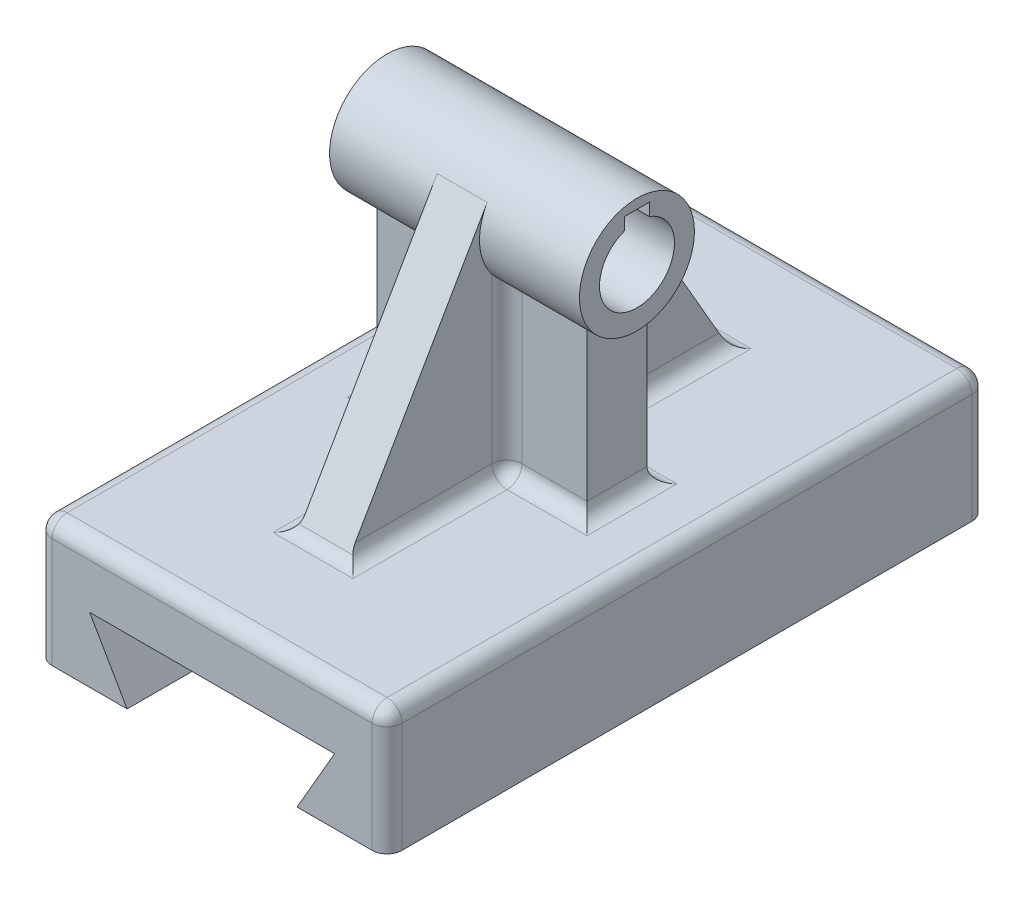
from build123d import *

# Parameters (mm, degrees)
SKETCH1_W               = 70
SKETCH1_H               = 120
BOSS_EXTRUDE1_DEPTH     = 25
CUT_EXTRUDE1_DEPTH      = 61
CUT_EXTRUDE1_DEPTH_BACK = 61
BOSS_EXTRUDE6_DEPTH     = 25
BOSS_EXTRUDE7_DEPTH     = 21
RIB33_REACH             = 37
SKETCH10_WALL_W         = 128.291652
SKETCH10_WALL_H         = 10
FILLET1_R               = 3


with BuildPart() as part:
    # Sketch1 → Boss-Extrude1 (new body)
    with BuildSketch(Plane(origin=(0, 0, 0), x_dir=(1, 0, 0), z_dir=(0, 1, 0))):
        Rectangle(SKETCH1_W, SKETCH1_H)
    extrude(amount=BOSS_EXTRUDE1_DEPTH)

    # Sketch2 → Cut-Extrude1 (cut, two sides)
    with BuildSketch(Plane.XY) as cut_extrude1_sk:
        Polygon((-17, 0), (-24.505553, 13), (24.505553, 13), (17, 0), align=None)
    extrude(amount=CUT_EXTRUDE1_DEPTH, mode=Mode.SUBTRACT)
    extrude(cut_extrude1_sk.sketch, amount=-CUT_EXTRUDE1_DEPTH_BACK, mode=Mode.SUBTRACT)


with BuildPart() as body_2:
    # Sketch6 → Boss-Extrude6 (new, symmetric)
    with BuildSketch(Plane(origin=(0, 0, 0), x_dir=(0, 0, -1), z_dir=(1, 0, 0))):
        with BuildLine():
            ThreePointArc((11.5, 68), (-5.623611, 78.031201), (-6, 58.189292))
            ThreePointArc((-6, 58.189292), (0, 56.5), (6, 58.189292))
            ThreePointArc((6, 58.189292), (10.031201, 62.376389), (11.5, 68))
        make_face()
        with BuildLine():
            Line((-2.5, 75.071068), (-2.5, 77.571068))
            Line((-2.5, 77.571068), (2.5, 77.571068))
            Line((2.5, 77.571068), (2.5, 75.071068))
            ThreePointArc((2.5, 75.071068), (6.123724, 72.330127), (7.5, 68))
            ThreePointArc((7.5, 68), (-4.330127, 61.876276), (-2.5, 75.071068))
        make_face(mode=Mode.SUBTRACT)
    extrude(amount=BOSS_EXTRUDE6_DEPTH, both=True)


with BuildPart() as body_3:
    # Sketch6_3 → Boss-Extrude7 (new body)
    with BuildSketch(Plane(origin=(0, 0, 0), x_dir=(0, 0, -1), z_dir=(1, 0, 0))):
        with BuildLine():
            Line((-6, 58.189292), (-6, 25))
            Line((-6, 25), (6, 25))
            Line((6, 25), (6, 58.189292))
            ThreePointArc((6, 58.189292), (0, 56.5), (-6, 58.189292))
        make_face()
    extrude(amount=BOSS_EXTRUDE7_DEPTH)

    # Mirror4: body 3 across plane


with BuildPart() as body_3_1:
    add(body_3.part)
    add(body_3.part.mirror(Plane(origin=(0, 0, 0), x_dir=(0, 0, 1), z_dir=(1, 0, 0))))


with BuildPart() as body_2_1:
    add(body_2.part)

    # Combine2: union body 3, part
    add(body_3_1.part)
    add(part.part)

    # Sketch10 wall → Rib33 (add, up to next)
    with BuildSketch(Plane(origin=(0, 49.375, 24.032205), x_dir=(0, -0.866025, 0.5), z_dir=(0, -0.5, -0.866025)), mode=Mode.PRIVATE) as rib33_sk1:
        Rectangle(SKETCH10_WALL_W, SKETCH10_WALL_H)
    rib33_tool1 = extrude(rib33_sk1.sketch, amount=RIB33_REACH, mode=Mode.PRIVATE) - body_2_1.part
    rib33 = rib33_tool1.solids().sort_by_distance((0, 49.375, 24.032205))[0]
    add(rib33)

    # Mirror5: Rib33 across plane
    add(rib33.mirror(Plane.XY))

    # Fillet1
    fillet1_edges = [body_2_1.edges().sort_by_distance(p)[0] for p in [
        (5, 41.594646, -6),
        (5, 25, -22.052559),
        (-5, 41.594646, -6),
        (-5, 25, -22.052559),
        (0, 25, -38.105118),
        (13, 25, -6),
        (-21, 25, 0),
        (0, 25, -60),
        (-35, 25, 0),
        (21, 25, 0),
        (13, 25, 6),
        (0, 25, 60),
        (-35, 12.5, 60),
        (35, 25, 0),
        (35, 12.5, 60),
        (35, 12.5, -60),
        (-35, 12.5, -60),
        (-13, 25, 6),
        (5, 41.594646, 6),
        (5, 25, 22.052559),
        (-5, 25, 22.052559),
        (-5, 41.594646, 6),
        (0, 25, 38.105118),
        (-13, 25, -6),
    ]]
    fillet(fillet1_edges, radius=FILLET1_R)


solid = body_2_1.part
